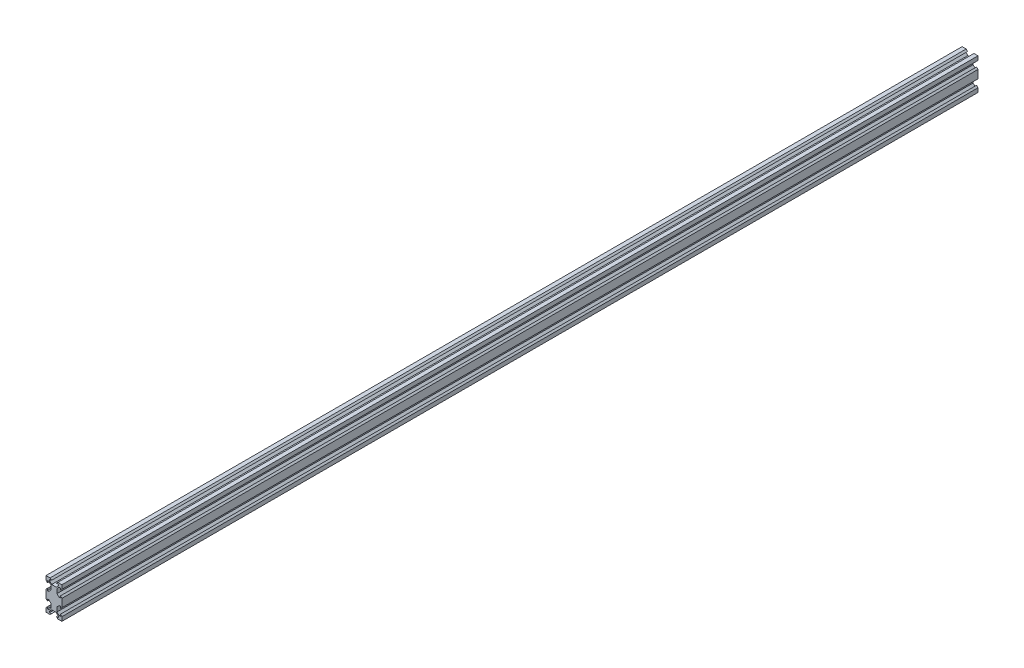
from build123d import *

# Parameters (mm, degrees)
SKETCH1_W           = 20
SKETCH1_H           = 40
BOSS_EXTRUDE1_DEPTH = 1153.3
CUT_EXTRUDE1_DEPTH  = 1154.3


with BuildPart() as part:
    # Sketch1 → Boss-Extrude1 (new body)
    with BuildSketch(Plane.XY):
        with Locations((10, 20)):
            Rectangle(SKETCH1_W, SKETCH1_H)
    extrude(amount=BOSS_EXTRUDE1_DEPTH)

    # Sketch2 → Cut-Extrude1 (cut, through all)
    with BuildSketch(Plane.XY.offset(1153.3)):
        Polygon((5.12, 40), (6.94, 38.18), (4.5, 38.18), (4.5, 36.475807358), (7.165807358, 33.81), (12.834192642, 33.81), (15.5, 36.475807358), (15.5, 38.18), (13.06, 38.18), (14.88, 40), align=None)
        Polygon((18.18, 35.5), (18.18, 33.06), (20, 34.88), (20, 25.12), (18.18, 26.94), (18.18, 24.5), (16.475807358, 24.5), (13.81, 27.165807358), (13.81, 32.834192642), (16.475807358, 35.5), align=None)
        Polygon((20, 14.88), (18.18, 13.06), (18.18, 15.5), (16.475807358, 15.5), (13.81, 12.834192642), (13.81, 7.165807358), (16.475807358, 4.5), (18.18, 4.5), (18.18, 6.94), (20, 5.12), align=None)
        Polygon((15.5, 1.82), (13.06, 1.82), (14.88, 0), (5.12, 0), (6.94, 1.82), (4.5, 1.82), (4.5, 3.524192642), (7.165807358, 6.19), (12.834192642, 6.19), (15.5, 3.524192642), align=None)
        Polygon((1.82, 4.5), (1.82, 6.94), (0, 5.12), (0, 14.88), (1.82, 13.06), (1.82, 15.5), (3.524192642, 15.5), (6.19, 12.834192642), (6.19, 7.165807358), (3.524192642, 4.5), align=None)
        Polygon((0, 25.12), (1.82, 26.94), (1.82, 24.5), (3.524192642, 24.5), (6.19, 27.165807358), (6.19, 32.834192642), (3.524192642, 35.5), (1.82, 35.5), (1.82, 33.06), (0, 34.88), align=None)
    extrude(amount=-CUT_EXTRUDE1_DEPTH, mode=Mode.SUBTRACT)


solid = part.part
